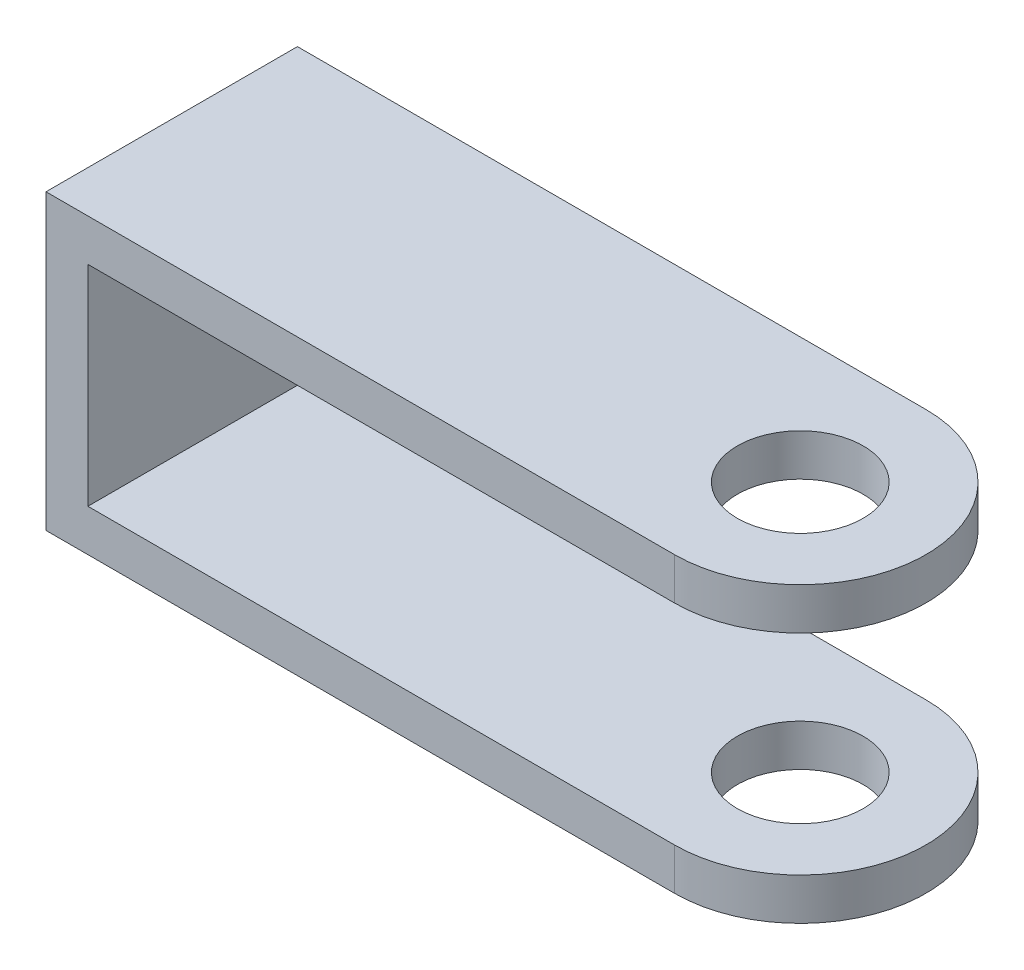
from build123d import *

# Parameters (mm, degrees)
SKETCH1_R           = 15
BOSS_EXTRUDE1_DEPTH = 10
SKETCH2_W           = 10
SKETCH2_H           = 60
BOSS_EXTRUDE2_DEPTH = 60


with BuildPart() as part:
    # Sketch1 → Boss-Extrude1 (new body)
    with BuildSketch(Plane(origin=(0, 0, 0), x_dir=(1, 0, 0), z_dir=(0, 1, 0))):
        with BuildLine():
            Line((0, 30), (0, -30))
            Line((0, -30), (150, -30))
            ThreePointArc((150, -30), (180, 0), (150, 30))
            Line((150, 30), (0, 30))
        make_face()
        with Locations((150, 0)):
            Circle(SKETCH1_R, mode=Mode.SUBTRACT)
    boss_extrude1 = extrude(amount=BOSS_EXTRUDE1_DEPTH)

    # Sketch2 → Boss-Extrude2 (add)
    with BuildSketch(Plane(origin=(0, 10, 0), x_dir=(1, 0, 0), z_dir=(0, 1, 0))):
        with Locations((5, 0)):
            Rectangle(SKETCH2_W, SKETCH2_H)
    extrude(amount=BOSS_EXTRUDE2_DEPTH)

    # Mirror2: Boss-Extrude1 across plane
    add(boss_extrude1.mirror(Plane.ZX.offset(35)))


solid = part.part
